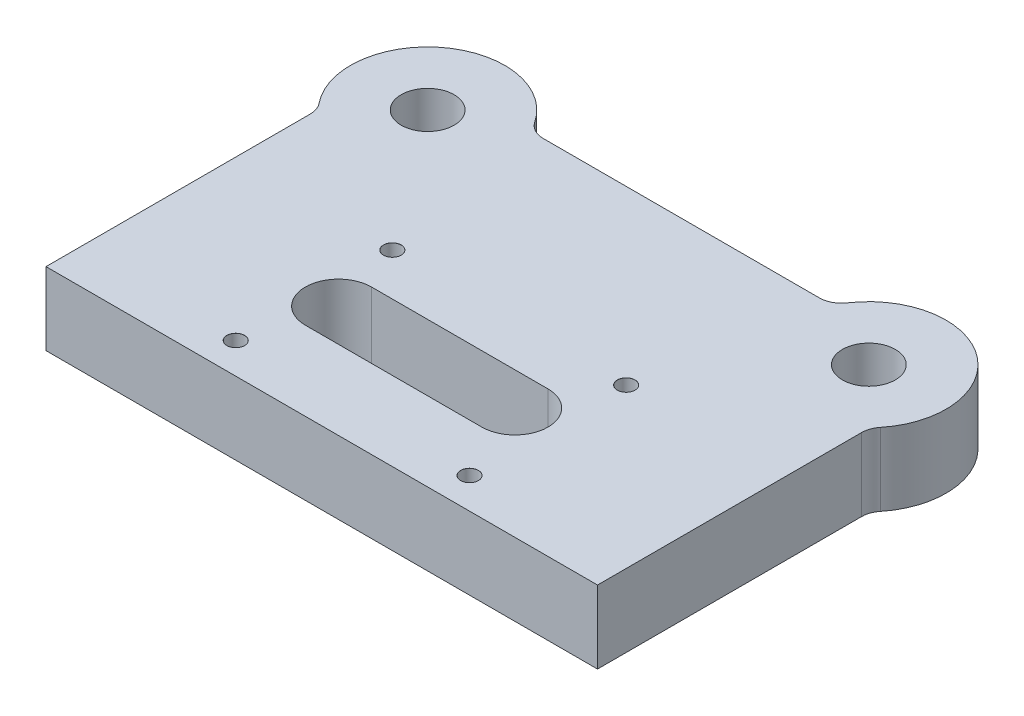
from build123d import *

# Parameters (mm, degrees)
SKETCH1_R                   = 12
BOSS_EXTRUDE1_DEPTH         = 33
FILLET1_R                   = 10
M8_TAPPED_HOLE2_D           = 8
M8_TAPPED_HOLE2_DEPTH       = 33
M8_TAPPED_HOLE2_CSINK_D     = 8.05
M8_TAPPED_HOLE2_CSINK_ANGLE = 90
CUT_EXTRUDE1_REACH          = 35


with BuildPart() as part:
    # Sketch1 → Boss-Extrude1 (new body)
    with BuildSketch(Plane(origin=(0, 0, 0), x_dir=(1, 0, 0), z_dir=(0, 1, 0))):
        with BuildLine():
            Line((125, 0), (-125, 0))
            Line((-125, 0), (-125, 123.505102572))
            ThreePointArc((-125, 123.505102572), (-120.023162168, 176.706671295), (-68.377223398, 163))
            Line((-68.377223398, 163), (68.377223398, 163))
            ThreePointArc((68.377223398, 163), (120.023162168, 176.706671295), (125, 123.505102572))
            Line((125, 123.505102572), (125, 0))
        make_face()
        with Locations((-100, 148)):
            Circle(SKETCH1_R, mode=Mode.SUBTRACT)
        with Locations((100, 148)):
            Circle(SKETCH1_R, mode=Mode.SUBTRACT)
    extrude(amount=BOSS_EXTRUDE1_DEPTH)

    # Fillet1
    fillet1_edges = [part.edges().sort_by_distance(p)[0] for p in [
        (-125, 16.5, -123.505102572),
        (-68.377223398, 16.5, -163),
        (68.377223398, 16.5, -163),
        (125, 16.5, -123.505102572),
    ]]
    fillet(fillet1_edges, radius=FILLET1_R)

    # M8 Tapped Hole2
    with Locations(Plane(origin=(0, 33, 0), x_dir=(1, 0, 0), z_dir=(0, 1, 0))):
        with Locations((-53, 85), (53, 85), (53, 14), (-53, 14)):
            CounterSinkHole(M8_TAPPED_HOLE2_D / 2, M8_TAPPED_HOLE2_CSINK_D / 2, depth=M8_TAPPED_HOLE2_DEPTH, counter_sink_angle=M8_TAPPED_HOLE2_CSINK_ANGLE)

    # Sketch6 → Cut-Extrude1 (cut, up to next)
    with BuildSketch(Plane(origin=(0, 33, 0), x_dir=(1, 0, 0), z_dir=(0, 1, 0)), mode=Mode.PRIVATE) as cut_extrude1_sk1:
        with BuildLine():
            Line((-43.216947182, 65.77208412), (36.783052818, 65.77208412))
            ThreePointArc((36.783052818, 65.77208412), (51.783052818, 50.77208412), (36.783052818, 35.77208412))
            Line((36.783052818, 35.77208412), (-43.216947182, 35.77208412))
            ThreePointArc((-43.216947182, 35.77208412), (-58.216947182, 50.77208412), (-43.216947182, 65.77208412))
        make_face()
    cut_extrude1_tool1 = extrude(cut_extrude1_sk1.sketch, amount=-CUT_EXTRUDE1_REACH, mode=Mode.PRIVATE) & part.part
    add(cut_extrude1_tool1.solids().sort_by_distance((-3.216947, 33, -50.772084))[0], mode=Mode.SUBTRACT)


solid = part.part
